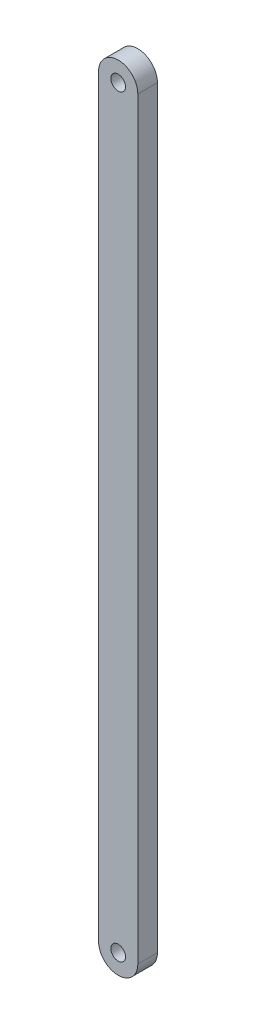
from build123d import *

# Parameters (mm, degrees)
SKETCH1_R           = 4.7625
BOSS_EXTRUDE1_DEPTH = 12.7


with BuildPart() as part:
    # Sketch1 → Boss-Extrude1 (new body)
    with BuildSketch(Plane.XY):
        with BuildLine():
            Line((12.7, 243.84), (12.7, -243.84))
            ThreePointArc((12.7, -243.84), (0, -256.54), (-12.7, -243.84))
            Line((-12.7, -243.84), (-12.7, 243.84))
            ThreePointArc((-12.7, 243.84), (0, 256.54), (12.7, 243.84))
        make_face()
        with Locations((0, 243.84)):
            Circle(SKETCH1_R, mode=Mode.SUBTRACT)
        with Locations((0, -243.84)):
            Circle(SKETCH1_R, mode=Mode.SUBTRACT)
    extrude(amount=BOSS_EXTRUDE1_DEPTH)


solid = part.part
